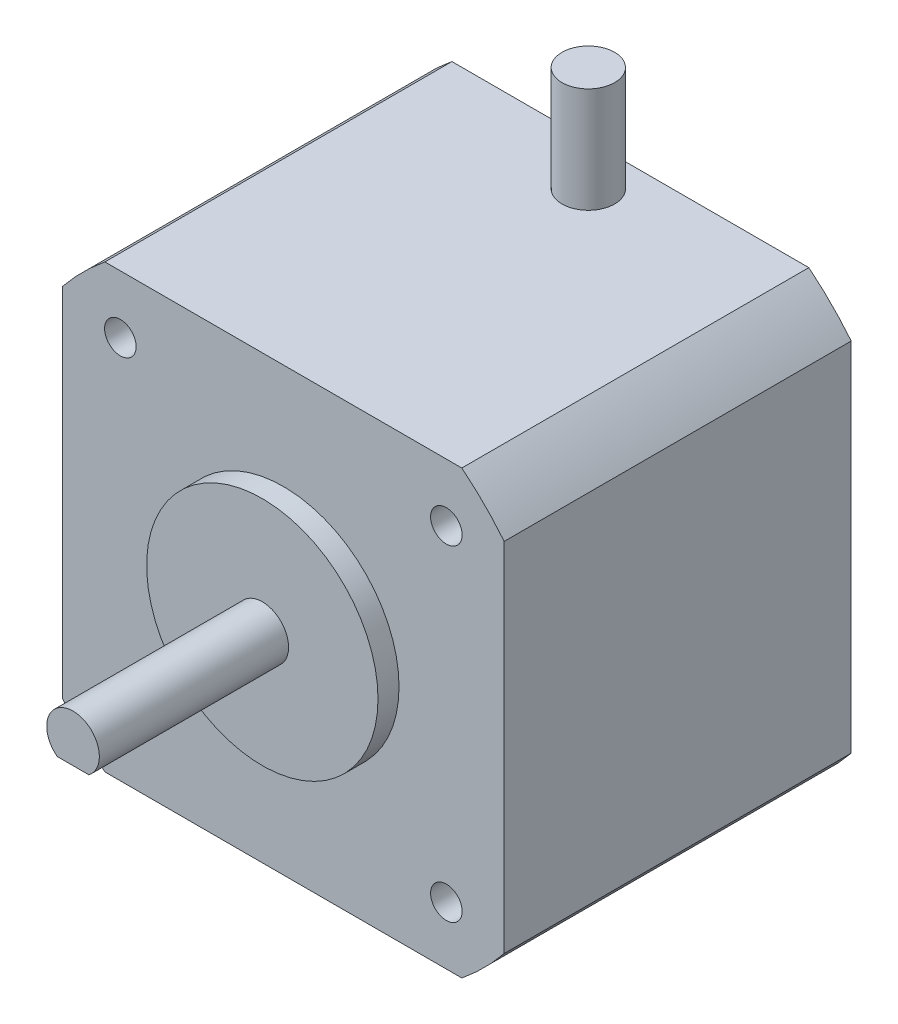
from build123d import *

# Parameters (mm, degrees)
SKETCH_1_W                   = 42
SKETCH_1_H                   = 42
EXTRUDE_1_DEPTH              = 33
SKETCH_2_R                   = 11
EXTRUDE_2_DEPTH              = 2
SKETCH_3_R                   = 2.5
EXTRUDE_3_DEPTH              = 18
CUT_EXTRUDE_2_DEPTH          = 18
HOLE_WIZARD_M3_1_D           = 2.5
HOLE_WIZARD_M3_1_DEPTH       = 7.5
HOLE_WIZARD_M3_1_CBORE_D     = 3
HOLE_WIZARD_M3_1_CBORE_DEPTH = 6
HOLE_WIZARD_M3_1_TIP         = 0.751075774
SKETCH_7_OUTSIDE_W           = 59.922
SKETCH_7_OUTSIDE_H           = 59.922
SKETCH_7_OUTSIDE_R           = 27
CUT_EXTRUDE_3_DEPTH          = 34
SKETCH_8_R                   = 2.5
EXTRUDE_4_DEPTH              = 10


with BuildPart() as part:
    # 草圖1 → 填料-伸長1 (new body)
    with BuildSketch(Plane.XY):
        Rectangle(SKETCH_1_W, SKETCH_1_H)
    extrude(amount=-EXTRUDE_1_DEPTH)

    # 草圖2 → 填料-伸長2 (add)
    with BuildSketch(Plane.XY):
        Circle(SKETCH_2_R)
    extrude(amount=EXTRUDE_2_DEPTH)

    # 草圖3 → 填料-伸長3 (add)
    with BuildSketch(Plane.XY.offset(2)):
        Circle(SKETCH_3_R)
    extrude(amount=EXTRUDE_3_DEPTH)

    # 草圖4 → 除料-伸長2 (cut)
    with BuildSketch(Plane.XY.offset(20)):
        with BuildLine():
            Line((1.5, -2), (-1.5, -2))
            ThreePointArc((-1.5, -2), (0, -2.5), (1.5, -2))
        make_face()
    extrude(amount=-CUT_EXTRUDE_2_DEPTH, mode=Mode.SUBTRACT)

    # M3 螺紋孔1
    with Locations(Plane.XY):
        with Locations((-15.5, 15.5), (15.5, 15.5), (15.5, -15.5), (-15.5, -15.5)):
            CounterBoreHole(HOLE_WIZARD_M3_1_D / 2, HOLE_WIZARD_M3_1_CBORE_D / 2, HOLE_WIZARD_M3_1_CBORE_DEPTH, depth=HOLE_WIZARD_M3_1_DEPTH)
            with Locations((0, 0, -(HOLE_WIZARD_M3_1_DEPTH + HOLE_WIZARD_M3_1_TIP / 2))):  # 118° drill point
                Cone(0, HOLE_WIZARD_M3_1_D / 2, HOLE_WIZARD_M3_1_TIP, mode=Mode.SUBTRACT)

    # 草圖7 outside → 除料-伸長3 (cut, through all)
    with BuildSketch(Plane.XY):
        Rectangle(SKETCH_7_OUTSIDE_W, SKETCH_7_OUTSIDE_H)
        Circle(SKETCH_7_OUTSIDE_R, mode=Mode.SUBTRACT)
    extrude(amount=-CUT_EXTRUDE_3_DEPTH, mode=Mode.SUBTRACT)

    # 草圖8 → 填料-伸長4 (add)
    with BuildSketch(Plane(origin=(0, 21, 0), x_dir=(1, 0, 0), z_dir=(0, 1, 0))):
        with Locations((0, 29)):
            Circle(SKETCH_8_R)
    extrude(amount=EXTRUDE_4_DEPTH)


solid = part.part
